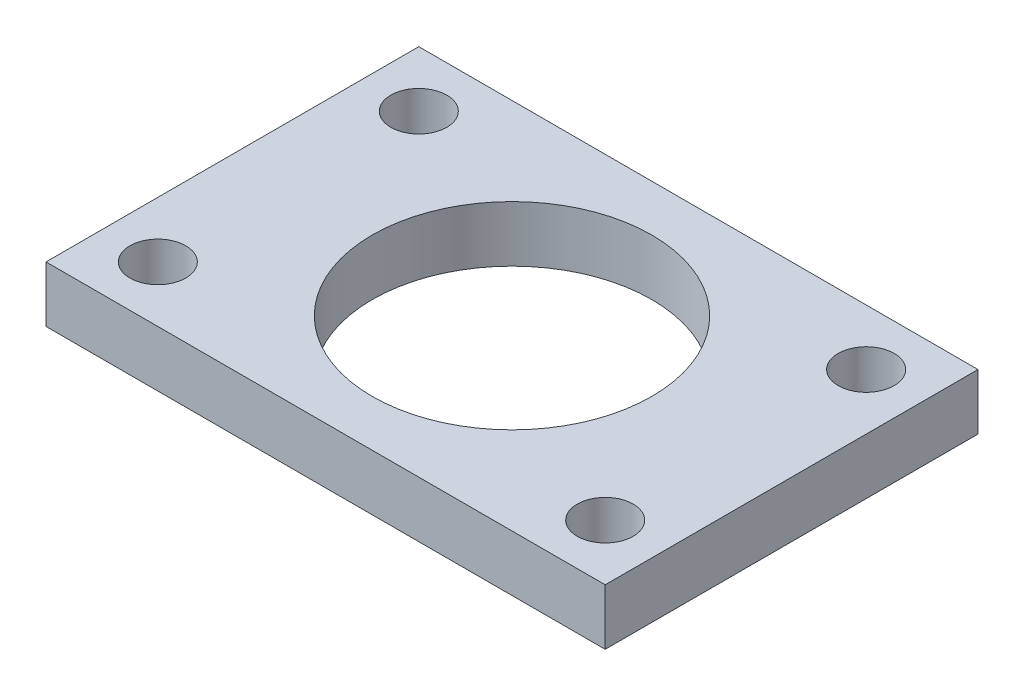
from build123d import *

# Parameters (mm, degrees)
SKETCH1_W               = 30
SKETCH1_H               = 20
BOSS_EXTRUDE1_DEPTH     = 3
SKETCH2_R               = 1.5
SKETCH2_R_2             = 7.5
CUT_EXTRUDE1_DEPTH      = 3
CUT_EXTRUDE1_DEPTH_BACK = 23


with BuildPart() as part:
    # Sketch1 → Boss-Extrude1 (new body)
    with BuildSketch(Plane(origin=(0, 0, 0), x_dir=(1, 0, 0), z_dir=(0, 1, 0))):
        with Locations((-15, 10)):
            Rectangle(SKETCH1_W, SKETCH1_H)
    extrude(amount=BOSS_EXTRUDE1_DEPTH)

    # Sketch2 → Cut-Extrude1 (cut, two sides)
    with BuildSketch(Plane(origin=(0, 3, 0), x_dir=(1, 0, 0), z_dir=(0, 1, 0))) as cut_extrude1_sk:
        with Locations((-27, 17)):
            Circle(SKETCH2_R)
        with Locations((-27, 3)):
            Circle(SKETCH2_R)
        with Locations((-3, 3)):
            Circle(SKETCH2_R)
        with Locations((-3, 17)):
            Circle(SKETCH2_R)
        with Locations((-15, 10)):
            Circle(SKETCH2_R_2)
    extrude(amount=CUT_EXTRUDE1_DEPTH, mode=Mode.SUBTRACT)
    extrude(cut_extrude1_sk.sketch, amount=-CUT_EXTRUDE1_DEPTH_BACK, mode=Mode.SUBTRACT)


solid = part.part
